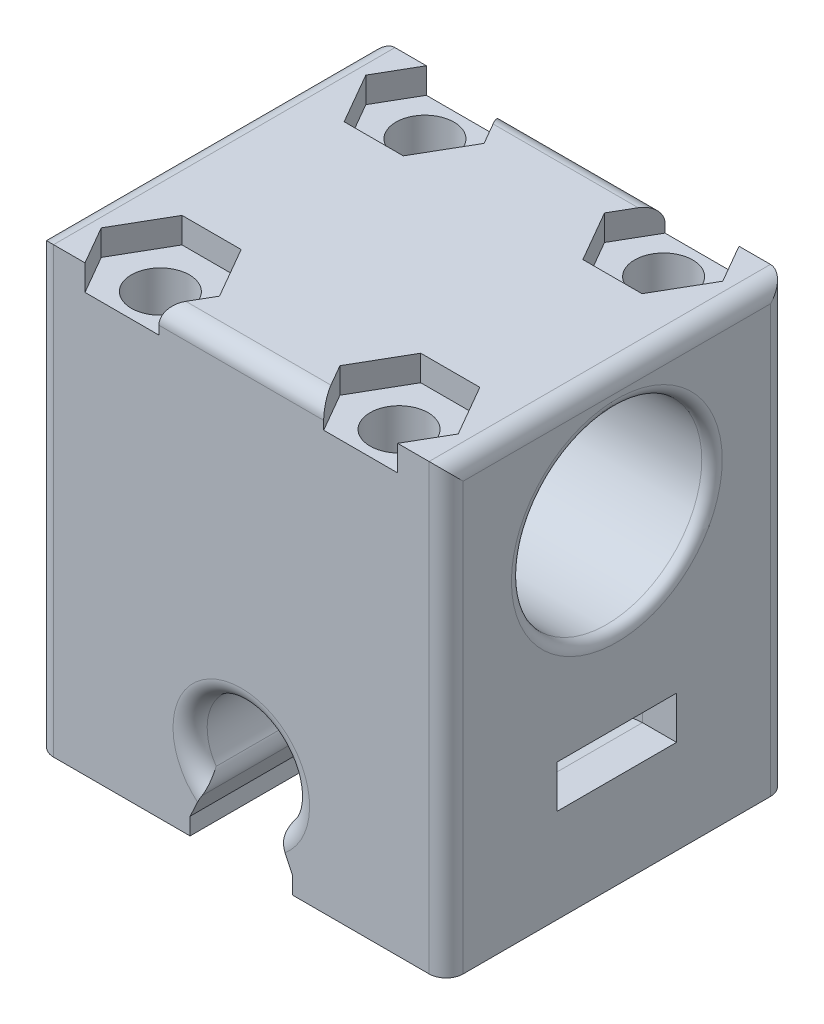
from build123d import *

# Parameters (mm, degrees)
CROQUIS1_W              = 24
CROQUIS1_H              = 19.999999388
SALIENTE_EXTRUIR1_DEPTH = 25
CORTAR_EXTRUIR1_DEPTH   = 60.75663166
CROQUIS4_R              = 1.7
CORTAR_EXTRUIR3_DEPTH   = 62.337415173
CROQUIS8_W              = 7
CROQUIS8_H              = 2.5
CORTAR_EXTRUIR7_DEPTH   = 1.5
CROQUIS3_R              = 5.575
CORTAR_EXTRUIR8_DEPTH   = 40
SALIENTE_EXTRUIR2_START = 1
CROQUIS13_W             = 9
CROQUIS13_H             = 19.999999388
CROQUIS13_R             = 1.7
CROQUIS13_W_2           = 2.5
CROQUIS13_H_2           = 7
SALIENTE_EXTRUIR2_DEPTH = 1
SALIENTE_EXTRUIR3_START = 1
CROQUIS14_W             = 9
CROQUIS14_H             = 19.999999388
CROQUIS14_R             = 1.7
CROQUIS14_W_2           = 2.5
CROQUIS14_H_2           = 7
SALIENTE_EXTRUIR3_DEPTH = 1
REDONDEO1_R             = 1
REDONDEO3_R             = 0.6


with BuildPart() as part:
    # Croquis1 → Saliente-Extruir1 (new body)
    with BuildSketch(Plane.XZ):
        with Locations((38.456466898, 14.319199476)):
            Rectangle(CROQUIS1_W, CROQUIS1_H)
    extrude(amount=-SALIENTE_EXTRUIR1_DEPTH)

    # Croquis2 → Cortar-Extruir1 (cut, through all)
    with BuildSketch(Plane.XY.offset(24.31919917)):
        with BuildLine():
            Line((35.456466898, 0), (36.335146555, 1.878679656))
            ThreePointArc((36.335146555, 1.878679656), (38.456466898, 7), (40.577787242, 1.878679656))
            Line((40.577787242, 1.878679656), (41.456466898, 0))
            Line((41.456466898, 0), (35.456466898, 0))
        make_face()
    extrude(amount=-CORTAR_EXTRUIR1_DEPTH, mode=Mode.SUBTRACT)

    # Croquis4 → Cortar-Extruir3 (cut, through all)
    with BuildSketch(Plane.XZ):
        with Locations(Location((31.464341614, 22.069199782, 0), (0, 0, 270))):
            Circle(CROQUIS4_R)
        with Locations(Location((45.448592182, 22.069199782, 0), (0, 0, 90))):
            Circle(CROQUIS4_R)
        with Locations(Location((45.448592182, 6.569198558, 0), (0, 0, 270))):
            Circle(CROQUIS4_R)
        with Locations(Location((31.464341614, 6.569198558, 0), (0, 0, 90))):
            Circle(CROQUIS4_R)
    extrude(amount=-CORTAR_EXTRUIR3_DEPTH, mode=Mode.SUBTRACT)

    # Cortar-Barrer2: sweep along a path in Croquis9
    with BuildLine(Plane(origin=(0, 0, 10.819199782), x_dir=(-1, 0, 0), z_dir=(0, 0, -1))) as cortar_barrer2_path:
        Line((-50.456466898, 6.999998763), (-48.456466898, 6.999998763))
        ThreePointArc((-48.456466898, 6.999998763), (-44.920932992, 5.535532669), (-43.456466898, 1.999998763))
        Line((-43.456466898, 1.999998763), (-43.456466898, -1.237e-06))
    # Croquis8 → Cortar-Barrer2 (sweep, cut)
    with BuildSketch(Plane(origin=(50.456466898, 0, 0), x_dir=(0, 0, -1), z_dir=(1, 0, 0))):
        with Locations((-14.319199782, 5.749998763)):
            Rectangle(CROQUIS8_W, CROQUIS8_H)
    cortar_barrer2 = sweep(path=cortar_barrer2_path.line, mode=Mode.SUBTRACT)

    # Simetría1: Cortar-Barrer2 across plane
    add(cortar_barrer2.mirror(Plane(origin=(38.456466898, 0, 0), x_dir=(0, 0, 1), z_dir=(1, 0, 0))), mode=Mode.SUBTRACT)

    # Croquis11 → Cortar-Extruir7 (cut)
    with BuildSketch(Plane(origin=(0, 25, 0), x_dir=(1, 0, 0), z_dir=(0, 1, 0))):
        Polygon((47.18064299, -19.069199782), (43.716541375, -19.069199782), (41.984490567, -22.069199782), (43.716541375, -25.069199782), (47.18064299, -25.069199782), (48.912693797, -22.069199782), align=None)
        Polygon((34.928443229, -22.069199782), (33.196392422, -19.069199782), (29.732290807, -19.069199782), (28.000239999, -22.069199782), (29.732290807, -25.069199782), (33.196392422, -25.069199782), align=None)
        Polygon((34.928443229, -6.569198558), (33.196392422, -3.569198558), (29.732290807, -3.569198558), (28.000239999, -6.569198558), (29.732290807, -9.569198558), (33.196392422, -9.569198558), align=None)
        Polygon((47.18064299, -9.569198558), (48.912693797, -6.569198558), (47.18064299, -3.569198558), (43.716541375, -3.569198558), (41.984490567, -6.569198558), (43.716541375, -9.569198558), align=None)
    extrude(amount=-CORTAR_EXTRUIR7_DEPTH, mode=Mode.SUBTRACT)

    # Croquis3 → Cortar-Extruir8 (cut)
    with BuildSketch(Plane(origin=(50.456466898, 0, 0), x_dir=(0, 0, -1), z_dir=(1, 0, 0))):
        with Locations((-14.31919917, 17.49999856)):
            Circle(CROQUIS3_R)
    extrude(amount=-CORTAR_EXTRUIR8_DEPTH, mode=Mode.SUBTRACT)

    # Croquis13 → Saliente-Extruir2 (add)
    with BuildSketch(Plane.XZ.offset(SALIENTE_EXTRUIR2_START)):
        with Locations((45.956466898, 14.319199476)):
            Rectangle(CROQUIS13_W, CROQUIS13_H)
        with Locations(Location((45.448592182, 22.069199782, 0), (0, 0, 270))):
            Circle(CROQUIS13_R, mode=Mode.SUBTRACT)
        with Locations(Location((45.448592182, 6.569198558, 0), (0, 0, 270))):
            Circle(CROQUIS13_R, mode=Mode.SUBTRACT)
        with Locations((44.706466898, 14.319199782)):
            Rectangle(CROQUIS13_W_2, CROQUIS13_H_2, mode=Mode.SUBTRACT)
    extrude(amount=-SALIENTE_EXTRUIR2_DEPTH)

    # Croquis14 → Saliente-Extruir3 (add)
    with BuildSketch(Plane.XZ.offset(SALIENTE_EXTRUIR3_START)):
        with Locations((30.956466898, 14.319199476)):
            Rectangle(CROQUIS14_W, CROQUIS14_H)
        with Locations(Location((31.464341614, 22.069199782, 0), (0, 0, 270))):
            Circle(CROQUIS14_R, mode=Mode.SUBTRACT)
        with Locations(Location((31.464341614, 6.569198558, 0), (0, 0, 270))):
            Circle(CROQUIS14_R, mode=Mode.SUBTRACT)
        with Locations((32.206466898, 14.319199782)):
            Rectangle(CROQUIS14_W_2, CROQUIS14_H_2, mode=Mode.SUBTRACT)
    extrude(amount=-SALIENTE_EXTRUIR3_DEPTH)

    # Redondeo1
    redondeo1_edges = [part.edges().sort_by_distance(p)[0] for p in [
        (38.456466898, 25, 24.31919917),
        (38.456466898, 25, 4.319199782),
        (26.456466898, 25, 14.319199476),
        (26.456466898, 12, 4.319199782),
        (26.456466898, 12, 24.31919917),
        (50.456466898, 12, 4.319199782),
        (50.456466898, 25, 14.319199476),
        (50.456466898, 12, 24.31919917),
        (40.577787242, 1.878679656, 14.319199476),
        (36.335146555, 1.878679656, 14.319199476),
        (38.456466898, 7, 4.319199782),
        (38.456466898, 7, 24.31919917),
    ]]
    fillet(redondeo1_edges, radius=REDONDEO1_R)

    # Redondeo3
    redondeo3_edges = [part.edges().sort_by_distance(p)[0] for p in [
        (26.456466898, 17.49999856, 19.89419917),
        (50.456466898, 17.49999856, 19.89419917),
    ]]
    fillet(redondeo3_edges, radius=REDONDEO3_R)


solid = part.part
